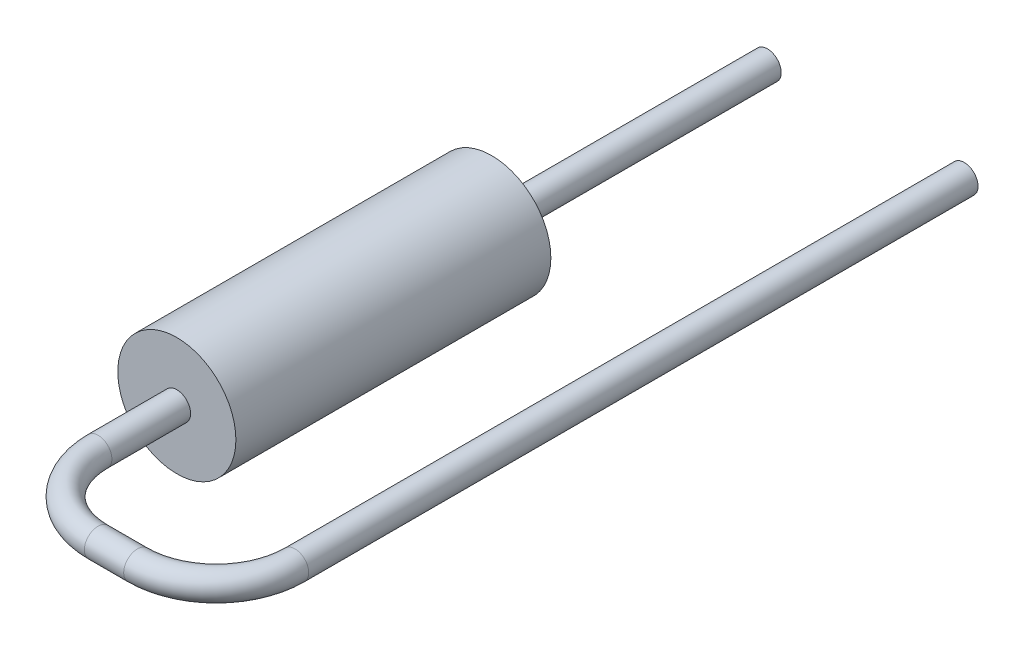
from build123d import *

# Parameters (mm, degrees)
SKETCH2_R           = 1.5
RESISTOR_BODY_DEPTH = 8
LEAD1_PROFILE_R     = 0.35
SKETCH6_R           = 0.35
LEAD2_DEPTH         = 7


with BuildPart() as part:
    # Sketch2 → Resistor Body (new body)
    with BuildSketch(Plane.XY):
        Circle(SKETCH2_R)
    extrude(amount=RESISTOR_BODY_DEPTH)

    # Lead1: sweep along a path in Lead1 Path
    with BuildLine(Plane(origin=(0, 0, 0), x_dir=(1, 0, 0), z_dir=(0, 1, 0))) as lead1_path:
        Line((0, -8), (0, -10))
        ThreePointArc((0, -10), (0.585786438, -11.414213562), (2, -12))
        Line((2, -12), (3, -12))
        ThreePointArc((3, -12), (4.414213562, -11.414213562), (5, -10))
        Line((5, -10), (5, 7))
    # Lead1 Profile → Lead1 (sweep)
    with BuildSketch(Plane(origin=(0, 0, 8), x_dir=(-1, 0, 0), z_dir=(0, 0, 1))):
        Circle(LEAD1_PROFILE_R)
    sweep(path=lead1_path.line)

    # Sketch6 → Lead2 (add)
    with BuildSketch(Plane(origin=(0, 0, 0), x_dir=(1, 0, 0), z_dir=(0, 0, -1))):
        Circle(SKETCH6_R)
    extrude(amount=LEAD2_DEPTH)


solid = part.part
